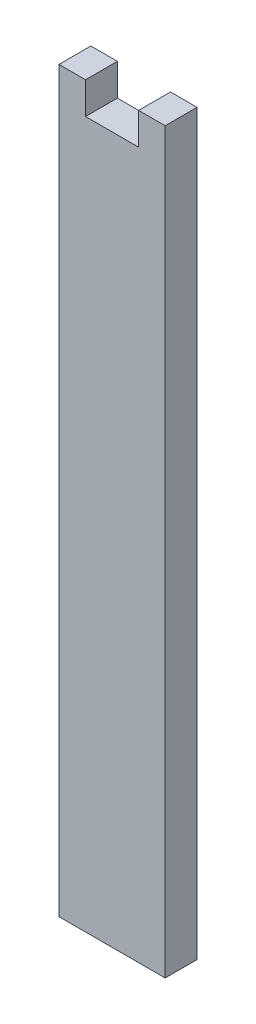
from build123d import *

# Parameters (mm, degrees)
SKETCH1_W           = 5
SKETCH1_H           = 6
BOSS_EXTRUDE1_DEPTH = 6


with BuildPart() as part:
    # Sketch1 → Boss-Extrude1 (new body)
    with BuildSketch(Plane.XY):
        Polygon((0, 63.5), (-5, 63.5), (-10, 63.5), (-10, -69.5), (10, -69.5), (10, 63.5), (5, 63.5), align=None)
        with Locations((-7.5, 66.5)):
            Rectangle(SKETCH1_W, SKETCH1_H)
        with Locations((7.5, 66.5)):
            Rectangle(SKETCH1_W, SKETCH1_H)
    extrude(amount=-BOSS_EXTRUDE1_DEPTH)


solid = part.part
